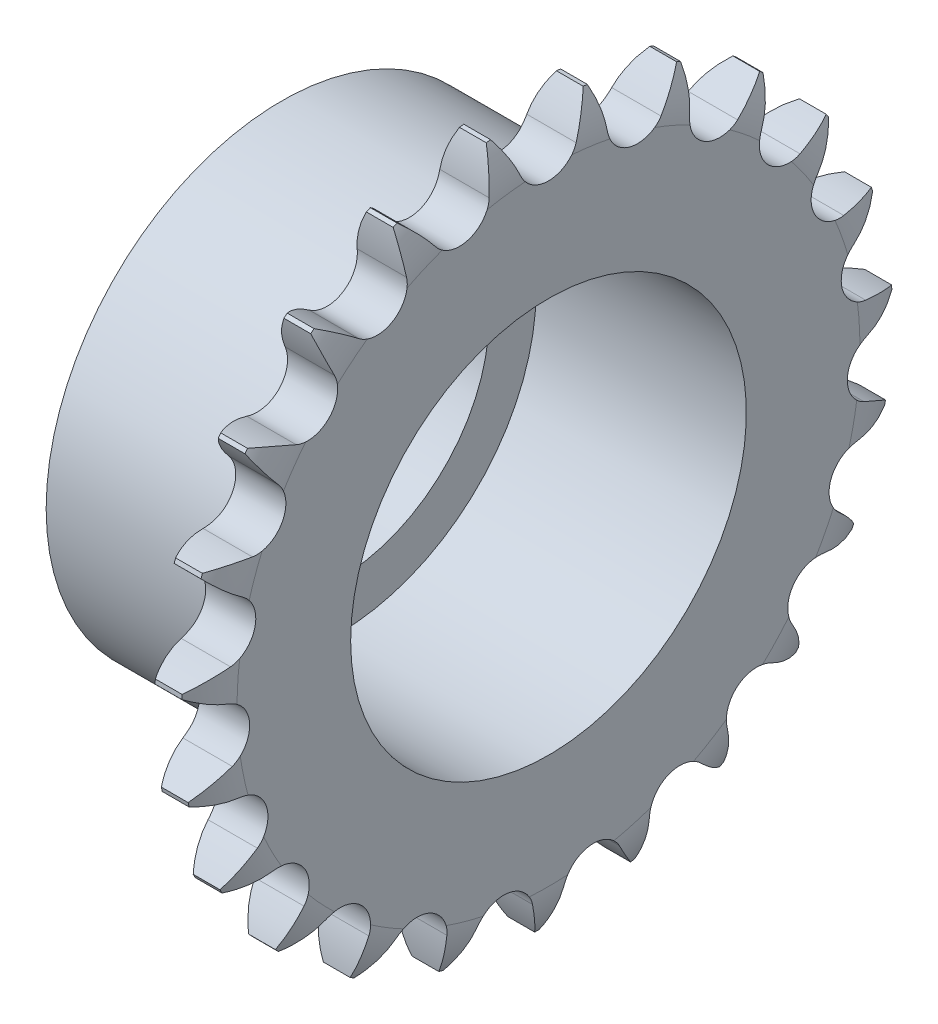
from build123d import *

# Parameters (mm, degrees)
TOOTHCUT_DEPTH     = 6.3196
TEETHCUTS_COUNT    = 23
TEETHCUTS_ANGLE    = 344.347826087
HUBNEAONESKE_R     = 25
HUBNEARONE_DEPTH   = 23
HUBNEARONEFILLET_R = 0.4
BORSKE_R           = 21
BORE_DEPTH         = 17.0005
CUT_EXTRUDE1_REACH = 8
SKETCH1_R          = 16


with BuildPart() as part:
    # BasProSke → Base-Revolve (revolve)
    with BuildSketch(Plane(origin=(0, 0, 0), x_dir=(1, 0, 0), z_dir=(0, 1, 0))):
        with BuildLine():
            Line((0, 0), (0, 33.05777326))
            ThreePointArc((0, 33.05777326), (0.314698702, 35.485936145), (1.238, 37.753649749))
            Line((1.238, 37.753649749), (4.0816, 37.753649749))
            ThreePointArc((4.0816, 37.753649749), (5.004901298, 35.485936145), (5.3196, 33.05777326))
            Line((5.3196, 33.05777326), (5.3196, 0))
            Line((5.3196, 0), (0, 0))
        make_face()
    revolve(axis=Axis((-10, 0, 0), (1, 0, 0)))

    # TooCutSke → ToothCut (cut, through all)
    with BuildSketch(Plane(origin=(0, 0, 0), x_dir=(0, 0, -1), z_dir=(1, 0, 0))):
        with BuildLine():
            ThreePointArc((2.97415754, 33.808261616), (3.980578959, 35.920428815), (5.23833278, 37.893292134))
            ThreePointArc((5.23833278, 37.893292134), (0, 38.253649749), (-5.23833278, 37.893292134))
            ThreePointArc((-5.23833278, 37.893292134), (-3.980578959, 35.920428815), (-2.97415754, 33.808261616))
            ThreePointArc((-2.97415754, 33.808261616), (0, 31.800524749), (2.97415754, 33.808261616))
        make_face()
    toothcut = extrude(amount=TOOTHCUT_DEPTH, mode=Mode.SUBTRACT)

    # TeethCuts: ToothCut ×23 about axis
    teethcuts_axis = Axis((-10, 0, 0), (1, 0, 0))
    for i in range(1, TEETHCUTS_COUNT):
        add(toothcut.rotate(teethcuts_axis, i * TEETHCUTS_ANGLE / (TEETHCUTS_COUNT - 1)), mode=Mode.SUBTRACT)

    # HubNeaOneSke → HubNearOne (add)
    with BuildSketch(Plane.ZY):
        Circle(HUBNEAONESKE_R)
    extrude(amount=HUBNEARONE_DEPTH)

    # HubNearOneFillet
    hubnearonefillet_edges = [part.edges().sort_by_distance(p)[0] for p in [
        (0, 0, -25),
    ]]
    fillet(hubnearonefillet_edges, radius=HUBNEARONEFILLET_R)

    # BorSke → Bore (cut, symmetric)
    with BuildSketch(Plane(origin=(0, 0, 0), x_dir=(0, 0, -1), z_dir=(1, 0, 0))):
        Circle(BORSKE_R)
    extrude(amount=BORE_DEPTH, both=True, mode=Mode.SUBTRACT)

    # Sketch1 → Cut-Extrude1 (cut, up to next)
    with BuildSketch(Plane(origin=(-17.0005, 0, 0), x_dir=(0, 0, -1), z_dir=(1, 0, 0)), mode=Mode.PRIVATE) as cut_extrude1_sk1:
        Circle(SKETCH1_R)
    cut_extrude1_tool1 = extrude(cut_extrude1_sk1.sketch, amount=-CUT_EXTRUDE1_REACH, mode=Mode.PRIVATE) & part.part
    add(cut_extrude1_tool1.solids().sort_by_distance((-17.0005, 0, 0))[0], mode=Mode.SUBTRACT)


solid = part.part
